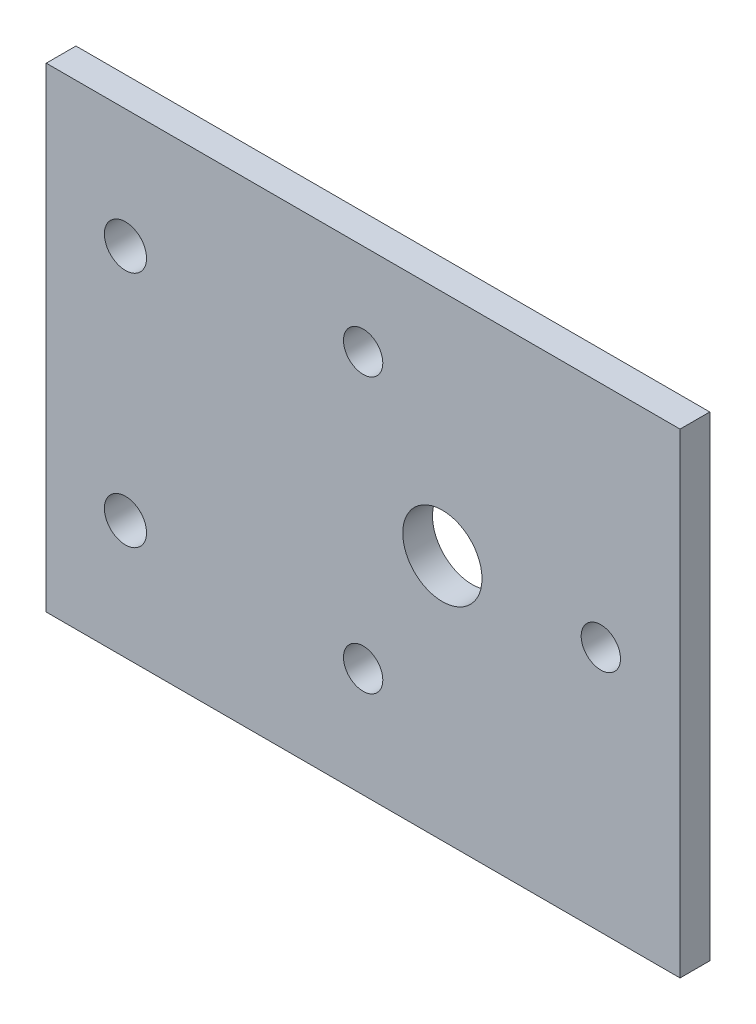
from build123d import *

# Parameters (mm, degrees)
SKETCH1_W           = 101.6
SKETCH1_H           = 76.2
BOSS_EXTRUDE1_DEPTH = 4.7625
SKETCH2_R           = 3.3782
CUT_EXTRUDE1_DEPTH  = 5.7625
SKETCH3_R           = 6.35
SKETCH3_R_2         = 3.1500064
CUT_EXTRUDE2_DEPTH  = 5.7625


with BuildPart() as part:
    # Sketch1 → Boss-Extrude1 (new body)
    with BuildSketch(Plane.XY):
        with Locations((50.8, 38.1)):
            Rectangle(SKETCH1_W, SKETCH1_H)
    extrude(amount=BOSS_EXTRUDE1_DEPTH)

    # Sketch2 → Cut-Extrude1 (cut, through all)
    with BuildSketch(Plane.XY.offset(4.7625)):
        with Locations((12.7, 57.15)):
            Circle(SKETCH2_R)
        with Locations((12.7, 19.05)):
            Circle(SKETCH2_R)
    extrude(amount=-CUT_EXTRUDE1_DEPTH, mode=Mode.SUBTRACT)

    # Sketch3 → Cut-Extrude2 (cut, through all)
    with BuildSketch(Plane.XY.offset(4.7625)):
        with Locations((63.5, 39.546877005)):
            Circle(SKETCH3_R)
        with Locations((50.8, 61.543922261)):
            Circle(SKETCH3_R_2)
        with Locations((88.9, 39.546877005)):
            Circle(SKETCH3_R_2)
        with Locations((50.8, 17.549831749)):
            Circle(SKETCH3_R_2)
    extrude(amount=-CUT_EXTRUDE2_DEPTH, mode=Mode.SUBTRACT)


solid = part.part
